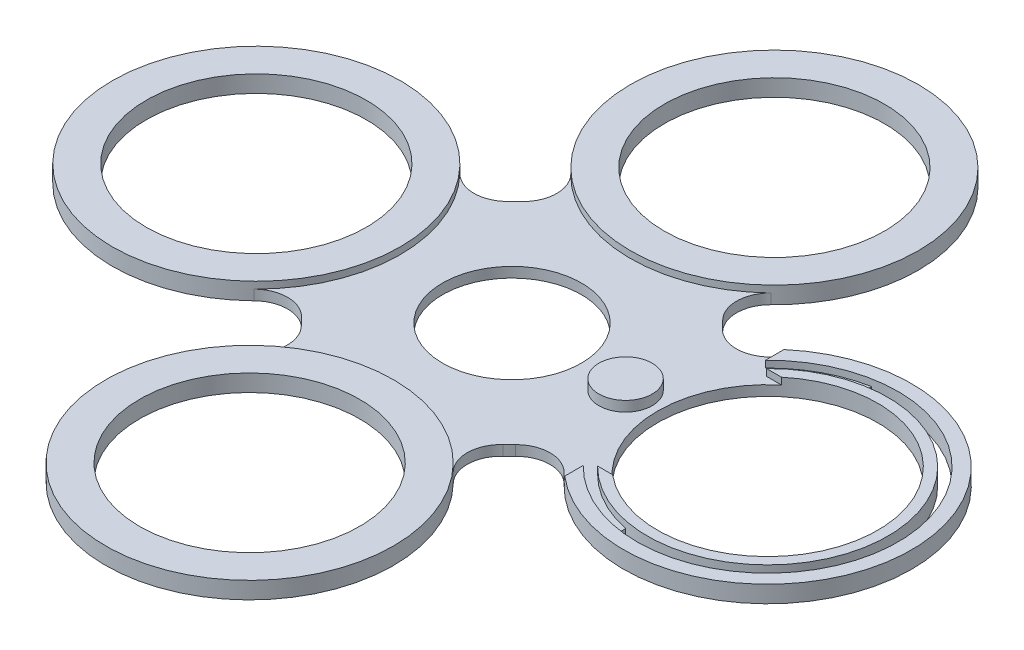
from build123d import *

# Parameters (mm, degrees)
IZIM1_R                     = 43.965787967
Y_KSEKLIK_EKSTR_ZYON1_DEPTH = 3
IZIM1_3_R                   = 42.5
IZIM1_3_R_2                 = 32.5
EKSTR_ZYON_NCE1_DEPTH       = 5
RADYUS1_R                   = 10
KES_EKSTR_ZYON1_DEPTH       = 3.0000001
KES_EKSTR_ZYON1_DEPTH_BACK  = 4.0000001
KES_EKSTR_ZYON2_DEPTH       = 2
KES_EKSTR_ZYON3_DEPTH       = 3.0000001
IZIM6_R                     = 20.5
KES_EKSTR_ZYON4_DEPTH       = 4.0000001
Y_KSEKLIK_EKSTR_ZYON4_DEPTH = 3


with BuildPart() as part:
    # Çizim1 → Yükseklik-Ekstrüzyon1 (new body)
    with BuildSketch(Plane(origin=(0, 0, 0), x_dir=(1, 0, 0), z_dir=(0, 1, 0))):
        Circle(IZIM1_R)
    extrude(amount=Y_KSEKLIK_EKSTR_ZYON1_DEPTH)

    # Çizim1<3> → Ekstrüzyon-İnce1 (add)
    with BuildSketch(Plane(origin=(0, 0, 0), x_dir=(1, 0, 0), z_dir=(0, 1, 0))):
        with Locations((76.459347515, -0.992424829)):
            Circle(IZIM1_3_R)
        with Locations((76.459347515, -0.992424829)):
            Circle(IZIM1_3_R_2, mode=Mode.SUBTRACT)
        with Locations((-0.992424829, -76.459347515)):
            Circle(IZIM1_3_R)
        with Locations((-0.992424829, -76.459347515)):
            Circle(IZIM1_3_R_2, mode=Mode.SUBTRACT)
        with Locations((-76.459347515, 0.992424829)):
            Circle(IZIM1_3_R)
        with Locations((-76.459347515, 0.992424829)):
            Circle(IZIM1_3_R_2, mode=Mode.SUBTRACT)
        with Locations((0.992424829, 76.459347515)):
            Circle(IZIM1_3_R)
        with Locations((0.992424829, 76.459347515)):
            Circle(IZIM1_3_R_2, mode=Mode.SUBTRACT)
    extrude(amount=EKSTR_ZYON_NCE1_DEPTH)

    # Radyus1
    radyus1_edges = [part.edges().sort_by_distance(p)[0] for p in [
        (-20.683952175, 1.5, 38.796451307),
        (19.670015447, 1.5, 39.320236569),
        (38.796451307, 1.5, 20.683952175),
        (39.320236569, 1.5, -19.670015447),
        (20.683952175, 1.5, -38.796451307),
        (-19.670015447, 1.5, -39.320236569),
        (-38.796451307, 1.5, -20.683952175),
        (-39.320236569, 1.5, 19.670015447),
    ]]
    fillet(radyus1_edges, radius=RADYUS1_R)

    # Çizim3 → Kes-Ekstrüzyon1 (cut, two sides)
    with BuildSketch(Plane(origin=(0, 3, 0), x_dir=(1, 0, 0), z_dir=(0, 1, 0))) as kes_ekstr_zyon1_sk:
        with BuildLine():
            Line((69.327141955, 36.841179861), (69.327141955, 33.783740052))
            ThreePointArc((69.327141955, 33.783740052), (111.959347515, -0.992424829), (69.327141955, -35.76858971))
            Line((69.327141955, -35.76858971), (69.327141955, -38.826029519))
            ThreePointArc((69.327141955, -38.826029519), (114.959347515, -0.992424829), (69.327141955, 36.841179861))
        make_face()
    extrude(amount=KES_EKSTR_ZYON1_DEPTH, mode=Mode.SUBTRACT)
    extrude(kes_ekstr_zyon1_sk.sketch, amount=-KES_EKSTR_ZYON1_DEPTH_BACK, mode=Mode.SUBTRACT)

    # Çizim4 → Kes-Ekstrüzyon2 (cut)
    with BuildSketch(Plane(origin=(0, 5, 0), x_dir=(1, 0, 0), z_dir=(0, 1, 0))):
        Polygon((48.909390592, -25.92206781), (55.608378692, -25.92206781), (55.608378692, 23.937218152), (48.909390592, 23.937218152), (48.909390592, 40.294217079), (36.28293528, 40.294217079), (36.28293528, 23.937218152), (27.96095337, 23.937218152), (27.96095337, -25.92206781), (36.28293528, -25.92206781), (36.28293528, -39.195058406), (48.909390592, -39.195058406), align=None)
    extrude(amount=-KES_EKSTR_ZYON2_DEPTH, mode=Mode.SUBTRACT)

    # Çizim3<4> → Kes-Ekstrüzyon3 (cut, through all)
    with BuildSketch(Plane(origin=(0, 3, 0), x_dir=(1, 0, 0), z_dir=(0, 1, 0))):
        with BuildLine():
            ThreePointArc((47.215527353, -26.033370944), (57.179387966, -34.317087765), (69.327141955, -38.826029519))
            Line((69.327141955, -38.826029519), (69.327141955, -35.76858971))
            ThreePointArc((69.327141955, -35.76858971), (58.437150617, -31.577558783), (49.494266586, -24.08212839))
            Line((49.494266586, -24.08212839), (47.215527353, -26.033370944))
        make_face()
        with BuildLine():
            Line((69.327141955, 33.783740052), (69.327141955, 36.841179861))
            ThreePointArc((69.327141955, 36.841179861), (57.316539714, 32.411211343), (47.42238732, 24.288100138))
            Line((47.42238732, 24.288100138), (49.685007595, 22.318189102))
            ThreePointArc((49.685007595, 22.318189102), (58.563030261, 29.666535179), (69.327141955, 33.783740052))
        make_face()
    extrude(amount=KES_EKSTR_ZYON3_DEPTH, mode=Mode.SUBTRACT)

    # Çizim6 → Kes-Ekstrüzyon4 (cut, through all)
    with BuildSketch(Plane(origin=(0, 3, 0), x_dir=(1, 0, 0), z_dir=(0, 1, 0))):
        Circle(IZIM6_R)
    extrude(amount=-KES_EKSTR_ZYON4_DEPTH, mode=Mode.SUBTRACT)

    # Çizim3<6> → Yükseklik-Ekstrüzyon4 (add)
    with BuildSketch(Plane(origin=(0, 3, 0), x_dir=(1, 0, 0), z_dir=(0, 1, 0))):
        with BuildLine():
            ThreePointArc((34.591220847, -8.293792461), (39.7514282, -5.784707132), (41.840982512, -0.44083102))
            ThreePointArc((41.840982512, -0.44083102), (39.820297101, 4.827467905), (34.794834124, 7.39317735))
            ThreePointArc((34.794834124, 7.39317735), (33.962927145, -0.44083102), (34.591220847, -8.293792461))
        make_face()
        with BuildLine():
            ThreePointArc((34.591220847, -8.293792461), (33.962927145, -0.44083102), (34.794834124, 7.39317735))
            ThreePointArc((34.794834124, 7.39317735), (26.08553532, -0.338584277), (34.591220847, -8.293792461))
        make_face()
    extrude(amount=Y_KSEKLIK_EKSTR_ZYON4_DEPTH)


solid = part.part
